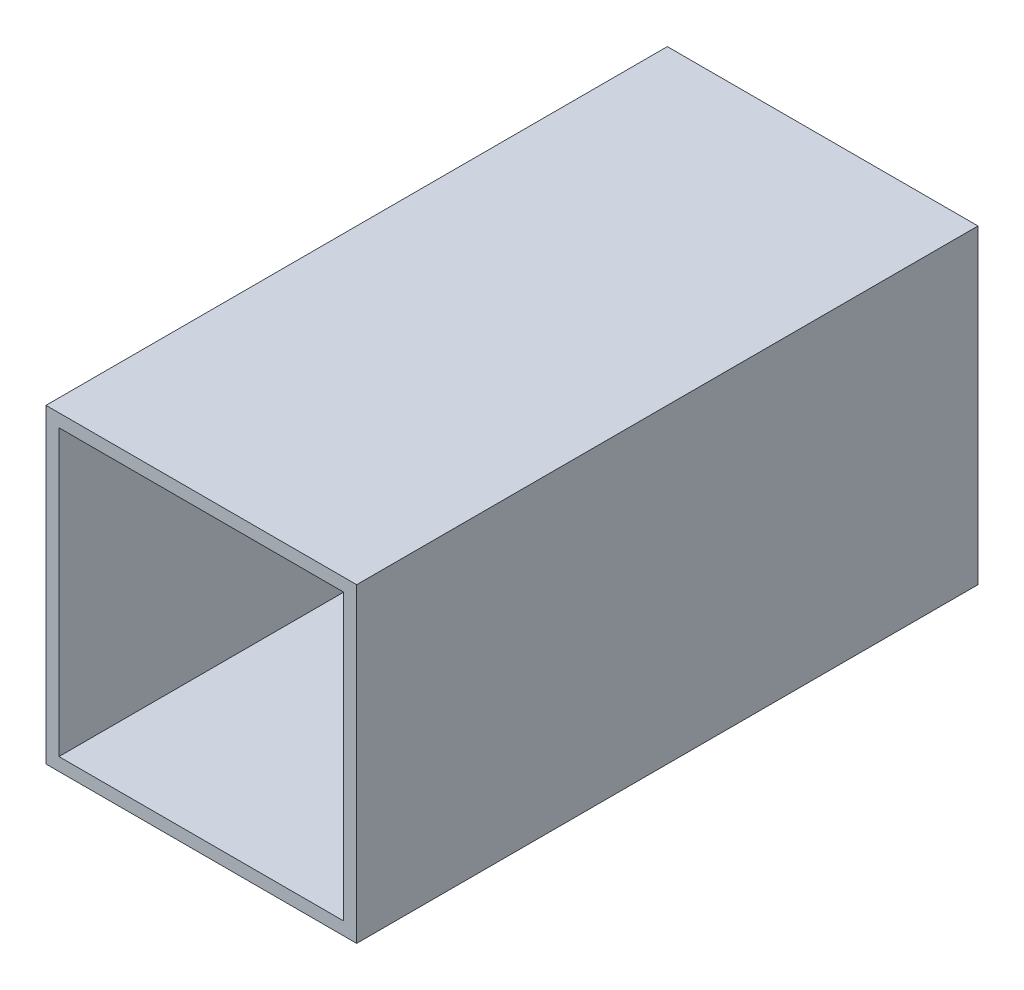
from build123d import *

# Parameters (mm, degrees)
SKETCH3_W                = 76.2
SKETCH3_H                = 76.2
SKETCH3_W_2              = 69.85
SKETCH3_H_2              = 69.85
BOSS_EXTRUDE1_DEPTH      = 76.2
BOSS_EXTRUDE1_DEPTH_BACK = 76.2


with BuildPart() as part:
    # Sketch3 → Boss-Extrude1 (new body, two sides)
    with BuildSketch(Plane.XY) as boss_extrude1_sk:
        Rectangle(SKETCH3_W, SKETCH3_H)
        Rectangle(SKETCH3_W_2, SKETCH3_H_2, mode=Mode.SUBTRACT)
    extrude(amount=BOSS_EXTRUDE1_DEPTH)
    extrude(boss_extrude1_sk.sketch, amount=-BOSS_EXTRUDE1_DEPTH_BACK)


solid = part.part
